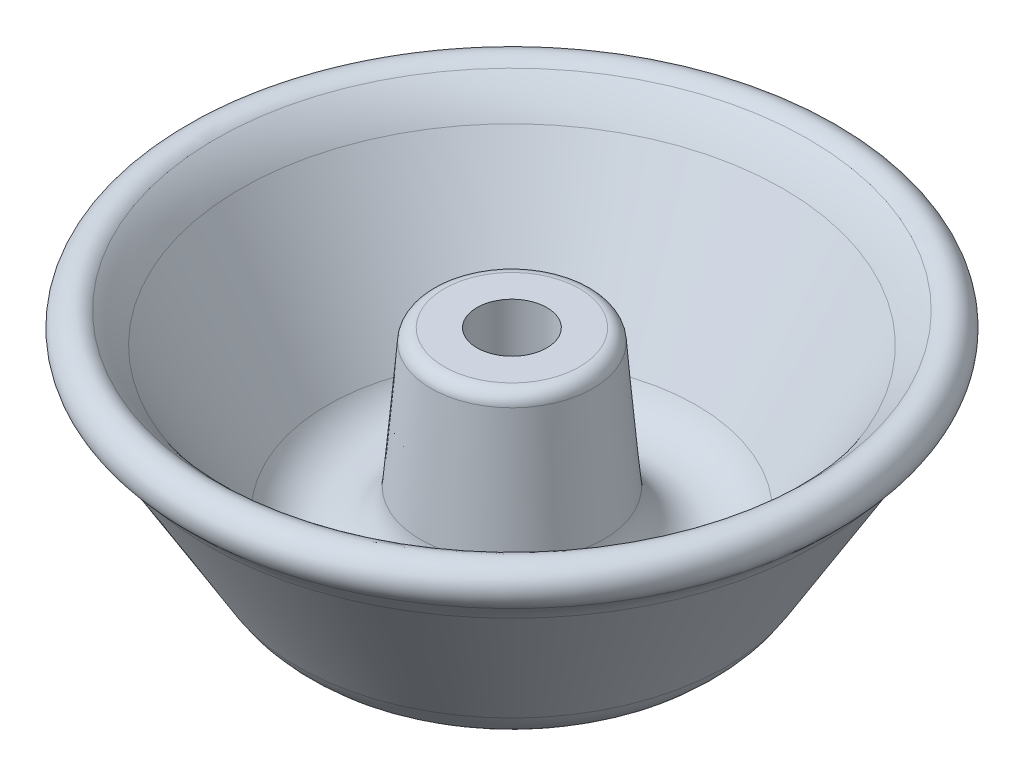
from build123d import *


with BuildPart() as part:
    # Sketch1 → Revolve1 (revolve)
    with BuildSketch(Plane.XY):
        with BuildLine():
            Line((4.1671875, 27.78125), (8.068328082, 27.78125))
            ThreePointArc((8.068328082, 27.78125), (9.141626789, 27.363444889), (9.649974712, 26.329949067))
            Line((9.649974712, 26.329949067), (10.936012635, 11.3955035))
            ThreePointArc((10.936012635, 11.3955035), (15.517839277, 6.108064367), (21.963417595, 8.82921635))
            Line((21.963417595, 8.82921635), (32.320255153, 25.982368789))
            ThreePointArc((32.320255153, 25.982368789), (33.693585684, 27.900042713), (35.349125676, 29.580131211))
            ThreePointArc((35.349125676, 29.580131211), (38.708256211, 29.341499324), (38.469624324, 25.982368789))
            ThreePointArc((38.469624324, 25.982368789), (37.336886434, 24.832834554), (36.397239229, 23.52074187))
            Line((36.397239229, 23.52074187), (25.542830946, 5.5435052))
            ThreePointArc((25.542830946, 5.5435052), (14.671345221, 0.048031702), (4.981912117, 7.430735608))
            ThreePointArc((4.981912117, 7.430735608), (4.372528694, 9.631716791), (4.1671875, 11.90625))
            Line((4.1671875, 11.90625), (4.1671875, 27.78125))
        make_face()
    revolve(axis=Axis((0, 0, 0), (0, 1, 0)))


solid = part.part
